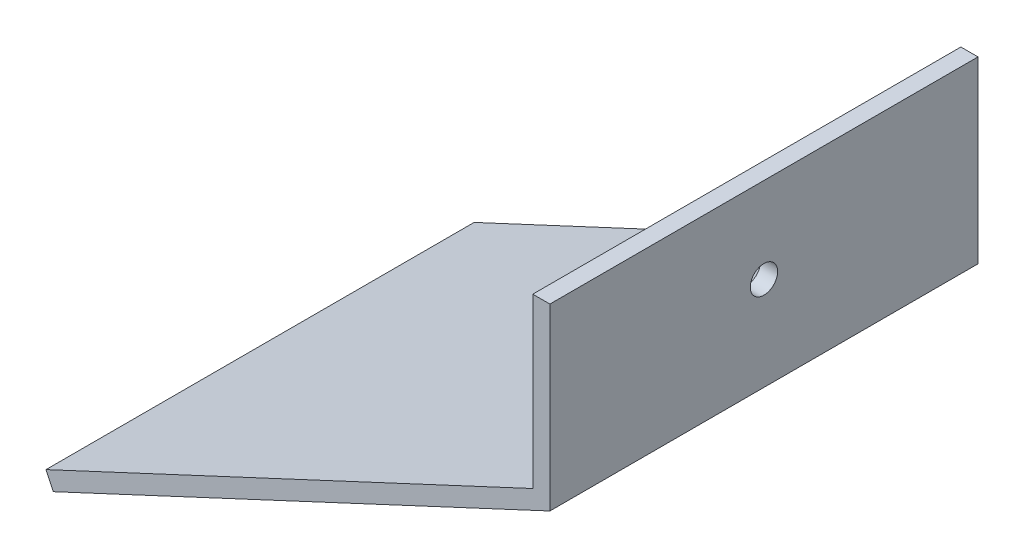
from build123d import *

# Parameters (mm, degrees)
EXTRUDE_1_DEPTH     = 25
SKETCH_2_R          = 1.6
CUT_EXTRUDE_1_DEPTH = 50


with BuildPart() as part:
    # ｽｹｯﾁ1 → ﾎﾞｽ - 押し出し1 (new body, symmetric)
    with BuildSketch(Plane.XY):
        Polygon((0, 0), (56.848934894, 26.509093699), (56.848934894, 46.167032185), (58.848934894, 46.167032185), (58.848934894, 25.234953177), (0.845236523, -1.812615574), align=None)
    extrude(amount=EXTRUDE_1_DEPTH, both=True)

    # ｽｹｯﾁ2 → ｶｯﾄ - 押し出し1 (cut)
    with BuildSketch(Plane(origin=(58.848934894, 0, 0), x_dir=(0, 0, -1), z_dir=(1, 0, 0))):
        with Locations((0, 36.167032185)):
            Circle(SKETCH_2_R)
    extrude(amount=-CUT_EXTRUDE_1_DEPTH, mode=Mode.SUBTRACT)


solid = part.part
